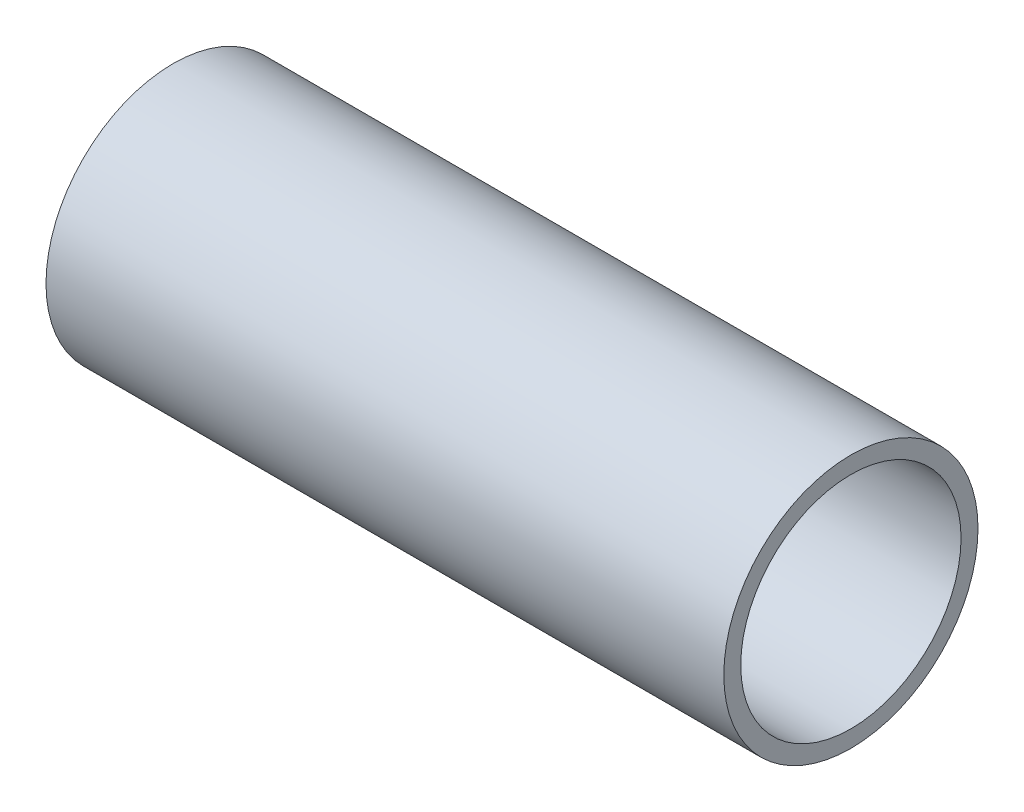
from build123d import *

# Parameters (mm, degrees)
SKETCH_1_R      = 22.5
SKETCH_1_R_2    = 19.5
EXTRUDE_1_DEPTH = 120


with BuildPart() as part:
    # Эскиз1 → Бобышка-Вытянуть1 (new body)
    with BuildSketch(Plane(origin=(0, 0, 0), x_dir=(0, 0, -1), z_dir=(1, 0, 0))):
        Circle(SKETCH_1_R)
        Circle(SKETCH_1_R_2, mode=Mode.SUBTRACT)
    extrude(amount=EXTRUDE_1_DEPTH)


solid = part.part
